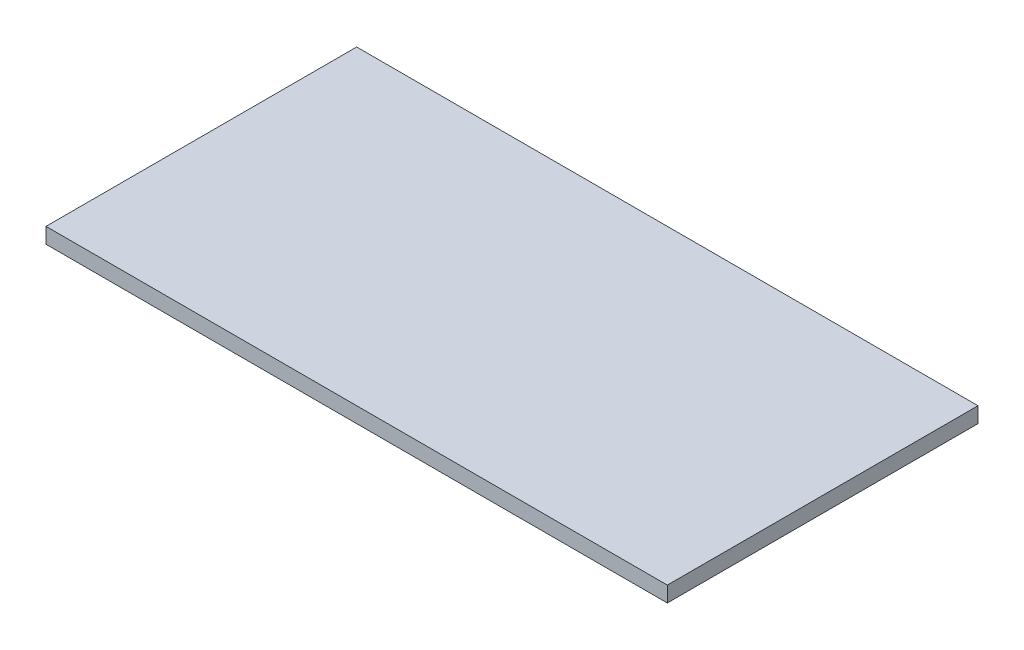
from build123d import *

# Parameters (mm, degrees)
SKETCH1_W           = 203.2
SKETCH1_H           = 101.6
BOSS_EXTRUDE1_DEPTH = 5.08


with BuildPart() as part:
    # Sketch1 → Boss-Extrude1 (new body)
    with BuildSketch(Plane(origin=(0, 0, 0), x_dir=(1, 0, 0), z_dir=(0, 1, 0))):
        with Locations((101.6, 50.8)):
            Rectangle(SKETCH1_W, SKETCH1_H)
    extrude(amount=BOSS_EXTRUDE1_DEPTH)


solid = part.part
